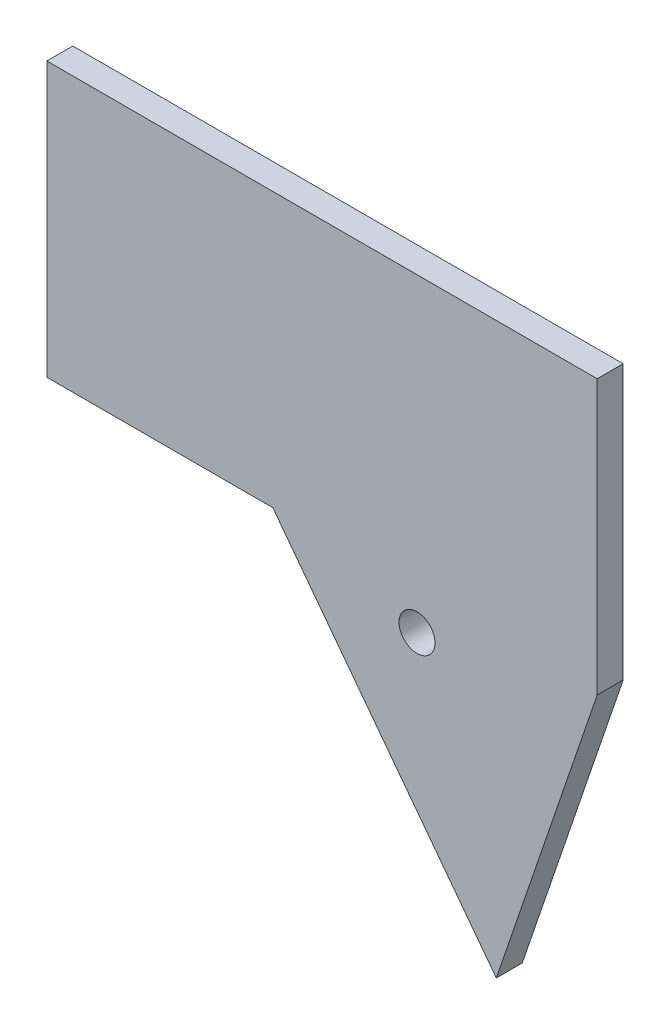
from build123d import *

# Parameters (mm, degrees)
SKETCH1_W           = 76.354636869
SKETCH1_H           = 38
SKETCH1_R           = 4.55
BOSS_EXTRUDE1_DEPTH = 3
SKETCH2_W           = 76.354636869
SKETCH2_H           = 38
BOSS_EXTRUDE2_DEPTH = 0.6
SKETCH3_R           = 3.5
CUT_EXTRUDE1_DEPTH  = 0.4
SKETCH4_R           = 2.5
BOSS_EXTRUDE3_DEPTH = 3.6


with BuildPart() as part:
    # Sketch1 → Boss-Extrude1 (new body)
    with BuildSketch(Plane.XY):
        with Locations((22.177318435, 0)):
            Rectangle(SKETCH1_W, SKETCH1_H)
        Circle(SKETCH1_R, mode=Mode.SUBTRACT)
    extrude(amount=BOSS_EXTRUDE1_DEPTH)

    # Sketch2 → Boss-Extrude2 (add)
    with BuildSketch(Plane(origin=(0, 0, 3), x_dir=(-1, 0, 0), z_dir=(0, 0, -1))):
        with Locations((-22.177318435, 0)):
            Rectangle(SKETCH2_W, SKETCH2_H)
    extrude(amount=-BOSS_EXTRUDE2_DEPTH)

    # Sketch3 → Cut-Extrude1 (cut)
    with BuildSketch(Plane(origin=(0, 0, 3), x_dir=(-1, 0, 0), z_dir=(0, 0, -1))):
        Circle(SKETCH3_R)
    extrude(amount=-CUT_EXTRUDE1_DEPTH, mode=Mode.SUBTRACT)

    # Sketch4 → Boss-Extrude3 (add)
    with BuildSketch(Plane(origin=(0, 0, 0), x_dir=(-1, 0, 0), z_dir=(0, 0, -1))):
        Polygon((-15.354636869, -19), (-46.354636869, -60), (-60.354636869, -19), align=None)
        with Locations((-35.354636869, -24)):
            Circle(SKETCH4_R, mode=Mode.SUBTRACT)
    extrude(amount=-BOSS_EXTRUDE3_DEPTH)


solid = part.part
